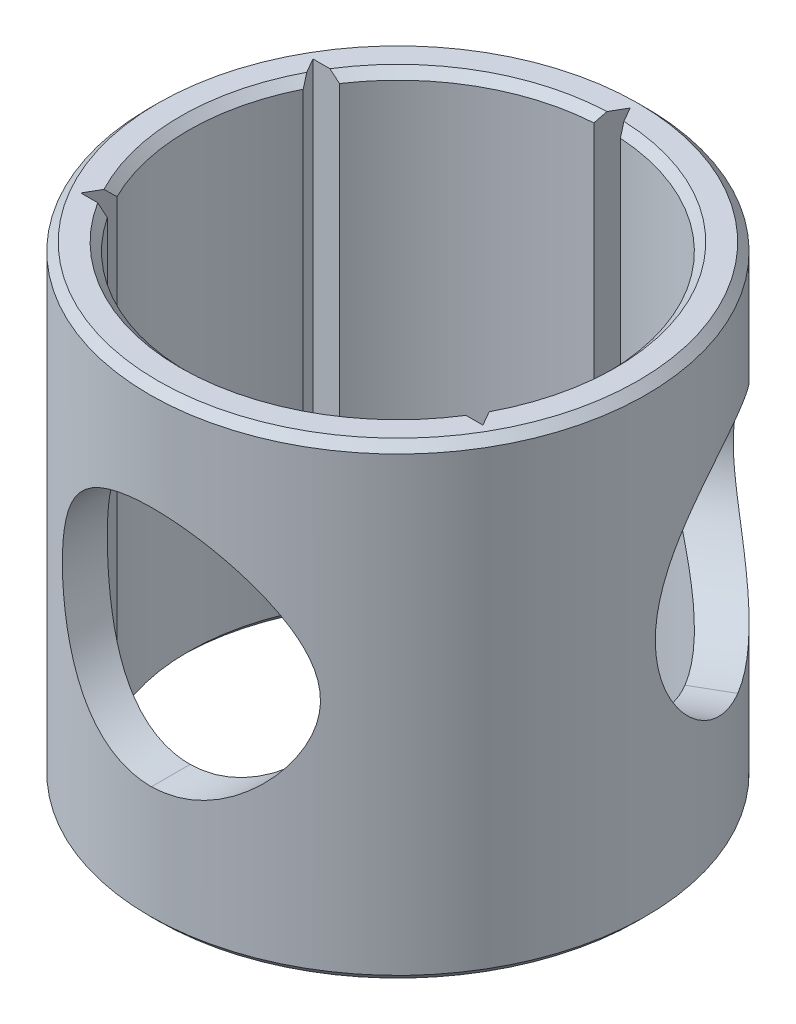
from build123d import *

# Parameters (mm, degrees)
SKIZZE1_R                       = 15.4
SKIZZE1_R_2                     = 13
AUFSATZ_LINEAR_AUSTRAGEN1_DEPTH = 29
SCHNITT_LINEAR_AUSTRAGEN1_DEPTH = 30
KREISMUSTER1_COUNT              = 6
SCHNITT_LINEAR_AUSTRAGEN2_DEPTH = 40
KREISMUSTER2_COUNT              = 2
KREISMUSTER2_ANGLE              = 120
FASE1_SIZE                      = 0.5


with BuildPart() as part:
    # Skizze1 → Aufsatz-Linear austragen1 (new body)
    with BuildSketch(Plane(origin=(0, 0, 0), x_dir=(1, 0, 0), z_dir=(0, 1, 0))):
        Circle(SKIZZE1_R)
        Circle(SKIZZE1_R_2, mode=Mode.SUBTRACT)
    extrude(amount=AUFSATZ_LINEAR_AUSTRAGEN1_DEPTH)

    # Skizze2 → Schnitt-Linear austragen1 (cut)
    with BuildSketch(Plane(origin=(0, 29, 0), x_dir=(1, 0, 0), z_dir=(0, 1, 0))):
        Polygon((0, 14.4), (-1.212435565, 12.3), (1.212435565, 12.3), align=None)
    schnitt_linear_austragen1 = extrude(amount=-SCHNITT_LINEAR_AUSTRAGEN1_DEPTH, mode=Mode.SUBTRACT)

    # Kreismuster1: Schnitt-Linear austragen1 ×6 about axis, 2 skipped
    kreismuster1_axis = Axis((0, 0, 0), (0, 1, 0))
    add([schnitt_linear_austragen1.rotate(kreismuster1_axis, i * 360 / KREISMUSTER1_COUNT) for i in range(1, KREISMUSTER1_COUNT) if i not in (3, 5)], mode=Mode.SUBTRACT)

    # Skizze4 → Schnitt-Linear austragen2 (cut)
    with BuildSketch(Plane.XY):
        with BuildLine():
            add(Edge.make_bspline(
                [(0.111060025, 22.5), (0.639300879, 22.5), (1.155677394, 22.445248159), (2.167064865, 22.237091412), (2.666545115, 22.080942317), (3.605989664, 21.688290409), (4.050194176, 21.451853076), (4.893446314, 20.905032787), (5.285125911, 20.59917097), (5.827575177, 20.099915553), (6.001199871, 19.926426342), (6.334425397, 19.564892818), (6.494571043, 19.37611554), (6.948382185, 18.793025727), (7.216655866, 18.38234153), (7.678212596, 17.504279407), (7.873119073, 17.03067888), (8.076117024, 16.289899143), (8.129271849, 16.037247788), (8.201601993, 15.517995542), (8.219931994, 15.254449012), (8.219373836, 14.733612639), (8.20081659, 14.474222401), (8.128221535, 13.95741094), (8.073943437, 13.70074198), (7.93793444, 13.20732613), (7.855909742, 12.96790589), (7.667704426, 12.500856046), (7.560934415, 12.272187735), (7.21175202, 11.609192865), (6.943084909, 11.199742989), (6.492879889, 10.621927107), (6.33479349, 10.435548798), (6.002244708, 10.074665182), (5.826984323, 9.899463309), (5.281731562, 9.397860606), (4.893307756, 9.09535099), (4.269746035, 8.690286916), (4.055023061, 8.563455953), (3.610577743, 8.327243912), (3.37961377, 8.217356465), (2.670822634, 7.9203305), (2.181766381, 7.766849611), (1.167202264, 7.556231906), (0.639334228, 7.5), (0.111060025, 7.5)],
                knots=[0, 0, 0, 0, 0.0625, 0.0625, 0.125, 0.125, 0.1875, 0.1875, 0.25, 0.25, 0.28125, 0.28125, 0.3125, 0.3125, 0.375, 0.375, 0.4375, 0.4375, 0.46875, 0.46875, 0.5, 0.5, 0.53125, 0.53125, 0.5625, 0.5625, 0.59375, 0.59375, 0.625, 0.625, 0.6875, 0.6875, 0.71875, 0.71875, 0.75, 0.75, 0.8125, 0.8125, 0.84375, 0.84375, 0.875, 0.875, 0.9375, 0.9375, 1, 1, 1, 1], degree=3))
            add(Edge.make_bspline(
                [(0.111060025, 7.5), (-0.390448327, 7.5), (-0.882142196, 7.549409538), (-1.846786236, 7.744105971), (-2.324101466, 7.892095257), (-3.218490264, 8.272179622), (-3.640194411, 8.504230194), (-4.435102241, 9.053198625), (-4.797963007, 9.363262244), (-5.290919717, 9.876843468), (-5.446890749, 10.056387063), (-5.742262296, 10.432848268), (-5.881325504, 10.629580644), (-6.265795523, 11.234360046), (-6.481935134, 11.660593869), (-6.747187548, 12.33706673), (-6.826058525, 12.570124504), (-6.961315382, 13.043113409), (-7.017489182, 13.281770455), (-7.15271788, 14.004210717), (-7.198868608, 14.494410817), (-7.199448336, 15.243418452), (-7.187937977, 15.494103354), (-7.14245933, 15.987185687), (-7.074564832, 16.475004835), (-6.962382705, 16.952612691), (-6.827561919, 17.425149461), (-6.748662835, 17.658846398), (-6.483025831, 18.337266083), (-6.266303639, 18.764968226), (-5.880230189, 19.372078328), (-5.740758514, 19.569163978), (-5.446184284, 19.944417008), (-5.290560393, 20.123537558), (-4.798392673, 20.636276772), (-4.435157623, 20.946735308), (-3.640693519, 21.495452919), (-3.220075027, 21.72683638), (-2.552756668, 22.010887407), (-2.324211269, 22.09497996), (-1.85413442, 22.241121071), (-1.612102928, 22.303083561), (-0.884217215, 22.450520557), (-0.390787068, 22.5), (0.111060025, 22.5)],
                knots=[0, 0, 0, 0, 0.0625, 0.0625, 0.125, 0.125, 0.1875, 0.1875, 0.25, 0.25, 0.28125, 0.28125, 0.3125, 0.3125, 0.375, 0.375, 0.40625, 0.40625, 0.4375, 0.4375, 0.5, 0.5, 0.53125, 0.53125, 0.5625, 0.59375, 0.59375, 0.625, 0.625, 0.6875, 0.6875, 0.71875, 0.71875, 0.75, 0.75, 0.8125, 0.8125, 0.875, 0.875, 0.90625, 0.90625, 0.9375, 0.9375, 1, 1, 1, 1], degree=3))
        make_face()
    schnitt_linear_austragen2 = extrude(amount=SCHNITT_LINEAR_AUSTRAGEN2_DEPTH, mode=Mode.SUBTRACT)

    # Kreismuster2: Schnitt-Linear austragen2 ×2 about axis
    kreismuster2_axis = Axis((0, 29, 0), (0, 1, 0))
    for i in range(1, KREISMUSTER2_COUNT):
        add(schnitt_linear_austragen2.rotate(kreismuster2_axis, i * KREISMUSTER2_ANGLE / (KREISMUSTER2_COUNT - 1)), mode=Mode.SUBTRACT)

    # Fase1
    fase1_edges = [part.edges().sort_by_distance(p)[0] for p in [
        (-6.5, 0, -11.258330249),
        (-15.4, 0, 0),
        (-13, 0, 0),
        (0, 0, 13),
        (11.258330249, 0, -6.5),
        (-13, 29, 0),
        (0, 29, 13),
        (11.258330249, 29, -6.5),
        (-15.4, 29, 0),
        (-6.5, 29, -11.258330249),
    ]]
    chamfer(fase1_edges, length=FASE1_SIZE)


solid = part.part
